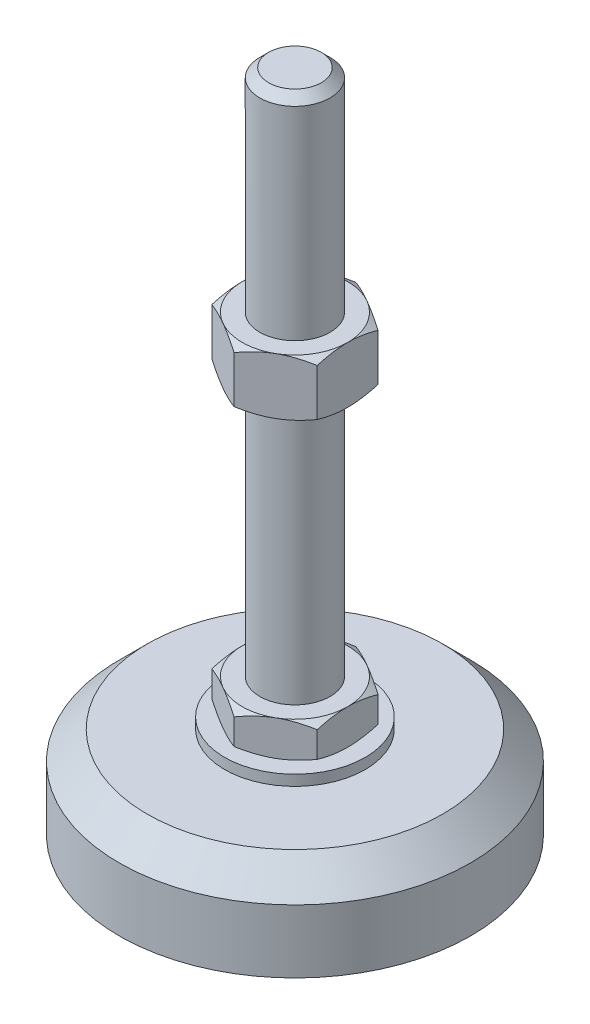
from build123d import *

# Parameters (mm, degrees)
EXTRUDE_1_DEPTH = 10
EXTRUDE_2_DEPTH = 16


with BuildPart() as part:
    # Эскиз1 → Повернуть1 (revolve)
    with BuildSketch(Plane.XY, mode=Mode.PRIVATE) as revolve_1_sk:
        Polygon((0, 0), (-50, 0), (-50, 18), (-42, 26), (-20, 26), (-20, 29), (-10, 29), (-10, 39), (-10, 186.5), (-7.5, 189), (0, 189), align=None)
    revolve(revolve_1_sk.sketch.rotate(Axis((0, 0, 0), (0, 1, 0)), 180), axis=Axis((0, 0, 0), (0, 1, 0)))  # turned: the seam where the file's is

    # Эскиз2 → Бобышка-Вытянуть1 (add)
    with BuildSketch(Plane(origin=(0, 29, 0), x_dir=(1, 0, 0), z_dir=(0, 1, 0))):
        Polygon((0, 17.320508076), (-15, 8.660254038), (-15, -8.660254038), (0, -17.320508076), (15, -8.660254038), (15, 8.660254038), align=None)
    extrude(amount=EXTRUDE_1_DEPTH)

    # Эскиз3 → Бобышка-Вытянуть2 (add)
    with BuildSketch(Plane(origin=(0, 112.75, 0), x_dir=(1, 0, 0), z_dir=(0, 1, 0))):
        Polygon((15, 8.660254038), (0, 17.320508076), (-15, 8.660254038), (-15, -8.660254038), (0, -17.320508076), (15, -8.660254038), align=None)
    extrude(amount=EXTRUDE_2_DEPTH)

    # Эскиз4 → Вырез-Повернуть2 (revolve, cut)
    with BuildSketch(Plane.XY, mode=Mode.PRIVATE) as cut_revolve_2_sk:
        Polygon((-28.856406461, 128.75), (-15, 128.75), (-28.856406461, 120.75), align=None)
        Polygon((-28.856406461, 112.75), (-28.856406461, 120.75), (-15, 112.75), align=None)
        Polygon((-23.660254038, 39), (-23.660254038, 34), (-15, 39), align=None)
        Polygon((-23.660254038, 34), (-23.660254038, 29), (-15, 29), align=None)
    revolve(cut_revolve_2_sk.sketch.rotate(Axis((0, 189, 0), (0, -1, 0)), 180), axis=Axis((0, 189, 0), (0, -1, 0)), mode=Mode.SUBTRACT)  # turned: the seam where the file's is


solid = part.part
